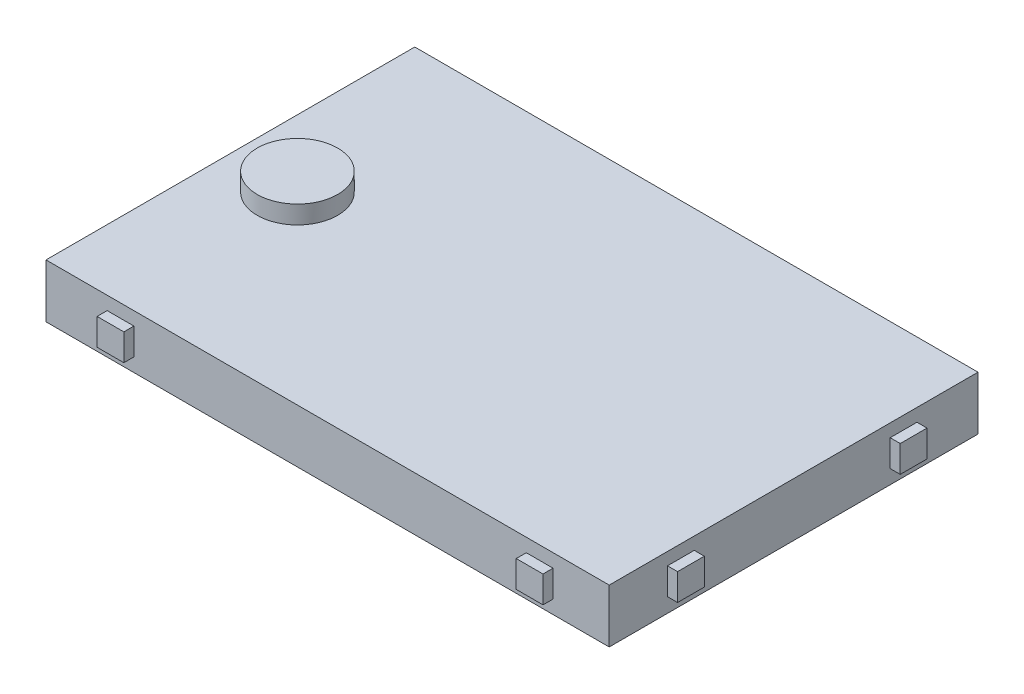
from build123d import *

# Parameters (mm, degrees)
SKETCH1_W           = 84
SKETCH1_H           = 55
BOSS_EXTRUDE1_DEPTH = 8
SKETCH2_W           = 3.987273362
SKETCH2_H           = 3.987273362
BOSS_EXTRUDE2_DEPTH = 1.5
SKETCH3_W           = 3.99
SKETCH3_H           = 3.99
BOSS_EXTRUDE3_DEPTH = 1.5
SKETCH6_W           = 3.99
SKETCH6_H           = 3.99
BOSS_EXTRUDE4_DEPTH = 1.5
SKETCH7_W           = 3.99
SKETCH7_H           = 3.99
BOSS_EXTRUDE5_DEPTH = 1.5
SKETCH10_R          = 6
BOSS_EXTRUDE6_DEPTH = 2.7


with BuildPart() as part:
    # Sketch1 → Boss-Extrude1 (new body)
    with BuildSketch(Plane(origin=(0, 0, 0), x_dir=(1, 0, 0), z_dir=(0, 1, 0))):
        Rectangle(SKETCH1_W, SKETCH1_H)
    extrude(amount=BOSS_EXTRUDE1_DEPTH)

    # Sketch2 → Boss-Extrude2 (add)
    with BuildSketch(Plane(origin=(0, -0.439186924, 27.5), x_dir=(1, 0, 0), z_dir=(0, 0, 1))):
        with Locations((-30.884576243, 4.455349568)):
            Rectangle(SKETCH2_W, SKETCH2_H)
    extrude(amount=BOSS_EXTRUDE2_DEPTH)

    # Sketch3 → Boss-Extrude3 (add)
    with BuildSketch(Plane(origin=(0, -0.590315395, 27.5), x_dir=(1, 0, 0), z_dir=(0, 0, 1))):
        with Locations((31.62769067, 4.58925653)):
            Rectangle(SKETCH3_W, SKETCH3_H)
    extrude(amount=BOSS_EXTRUDE3_DEPTH)

    # Sketch6 → Boss-Extrude4 (add)
    with BuildSketch(Plane(origin=(42, 0.101407509, -1.505913579), x_dir=(0, 0, -1), z_dir=(1, 0, 0))):
        with Locations((-18.317394251, 4.044008008)):
            Rectangle(SKETCH6_W, SKETCH6_H)
    extrude(amount=BOSS_EXTRUDE4_DEPTH)

    # Sketch7 → Boss-Extrude5 (add)
    with BuildSketch(Plane(origin=(42, -0.062003659, -3.114914247), x_dir=(0, 0, -1), z_dir=(1, 0, 0))):
        with Locations((13.283568203, 4.150096741)):
            Rectangle(SKETCH7_W, SKETCH7_H)
    extrude(amount=BOSS_EXTRUDE5_DEPTH)

    # Sketch10 → Boss-Extrude6 (add)
    with BuildSketch(Plane(origin=(0, 8, 0), x_dir=(1, 0, 0), z_dir=(0, 1, 0))):
        with Locations((-32, 0)):
            Circle(SKETCH10_R)
    extrude(amount=BOSS_EXTRUDE6_DEPTH)


solid = part.part
